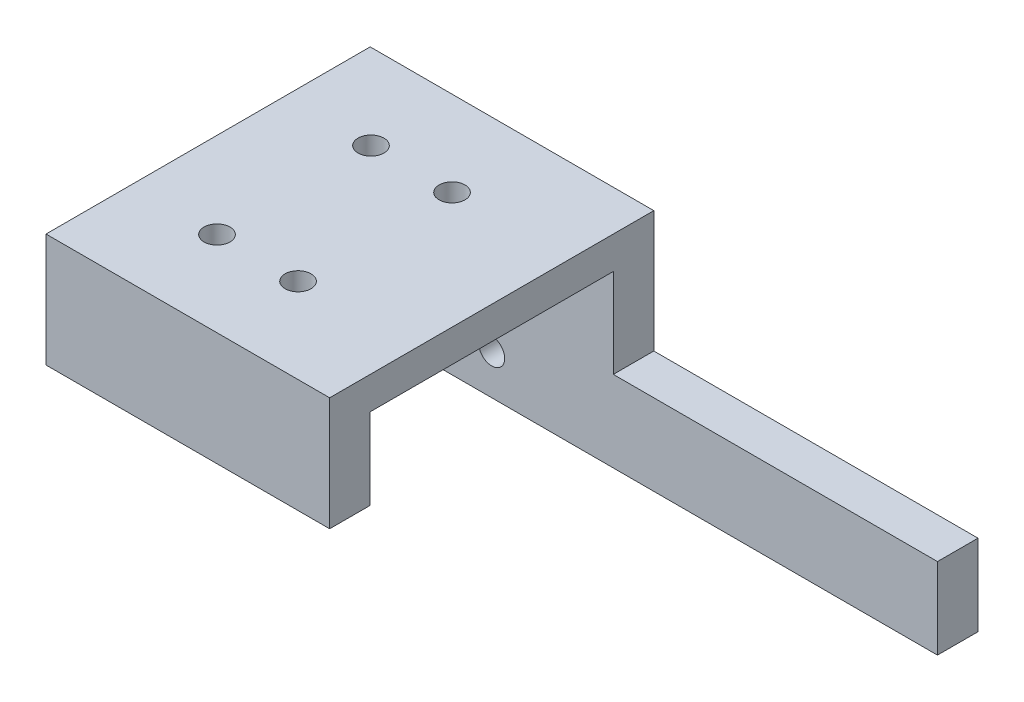
from build123d import *

# Parameters (mm, degrees)
SKETCH_1_W          = 35
SKETCH_1_H          = 40
EXTRUDE_1_DEPTH     = 4
SKETCH_2_R          = 1.6
CUT_EXTRUDE_1_DEPTH = 6
SKETCH_3_W          = 35
SKETCH_3_H          = 5
EXTRUDE_2_DEPTH     = 21
SKETCH_4_R          = 1.6
CUT_EXTRUDE_2_DEPTH = 15
SKETCH_5_R          = 2.8
CUT_EXTRUDE_3_DEPTH = 2
SKETCH_6_W          = 40
SKETCH_6_H          = 10
EXTRUDE_3_DEPTH     = 5
SKETCH_7_W          = 35
SKETCH_7_H          = 5
EXTRUDE_4_DEPTH     = 10


with BuildPart() as part:
    # 草图1 → 凸台-拉伸1 (new body)
    with BuildSketch(Plane(origin=(0, 0, 0), x_dir=(1, 0, 0), z_dir=(0, 1, 0))):
        with Locations((17.5, 20)):
            Rectangle(SKETCH_1_W, SKETCH_1_H)
    extrude(amount=EXTRUDE_1_DEPTH)

    # 草图2 → 切除-拉伸1 (cut)
    with BuildSketch(Plane(origin=(0, 4, 0), x_dir=(1, 0, 0), z_dir=(0, 1, 0))):
        with Locations((10.6, 29.5)):
            Circle(SKETCH_2_R)
        with Locations((20.6, 29.5)):
            Circle(SKETCH_2_R)
        with Locations((20.6, 10.5)):
            Circle(SKETCH_2_R)
        with Locations((10.6, 10.5)):
            Circle(SKETCH_2_R)
    extrude(amount=-CUT_EXTRUDE_1_DEPTH, mode=Mode.SUBTRACT)

    # 草图3 → 凸台-拉伸2 (add)
    with BuildSketch(Plane.XZ):
        with Locations((17.5, -37.5)):
            Rectangle(SKETCH_3_W, SKETCH_3_H)
    extrude(amount=EXTRUDE_2_DEPTH)

    # 草图4 → 切除-拉伸2 (cut)
    with BuildSketch(Plane(origin=(0, 0, -40), x_dir=(-1, 0, 0), z_dir=(0, 0, -1))):
        with Locations((-10, -16)):
            Circle(SKETCH_4_R)
        with Locations((-20, -16)):
            Circle(SKETCH_4_R)
    extrude(amount=-CUT_EXTRUDE_2_DEPTH, mode=Mode.SUBTRACT)

    # 草图5 → 切除-拉伸3 (cut)
    with BuildSketch(Plane(origin=(0, 0, -40), x_dir=(-1, 0, 0), z_dir=(0, 0, -1))):
        with Locations((-20, -16)):
            Circle(SKETCH_5_R)
        with Locations((-10, -16)):
            Circle(SKETCH_5_R)
    extrude(amount=-CUT_EXTRUDE_3_DEPTH, mode=Mode.SUBTRACT)

    # 草图6 → 凸台-拉伸3 (add)
    with BuildSketch(Plane(origin=(0, 0, -40), x_dir=(-1, 0, 0), z_dir=(0, 0, -1))):
        with Locations((-55, -16)):
            Rectangle(SKETCH_6_W, SKETCH_6_H)
    extrude(amount=-EXTRUDE_3_DEPTH)

    # 草图7 → 凸台-拉伸4 (add)
    with BuildSketch(Plane.XZ):
        with Locations((17.5, -2.5)):
            Rectangle(SKETCH_7_W, SKETCH_7_H)
    extrude(amount=EXTRUDE_4_DEPTH)


solid = part.part
